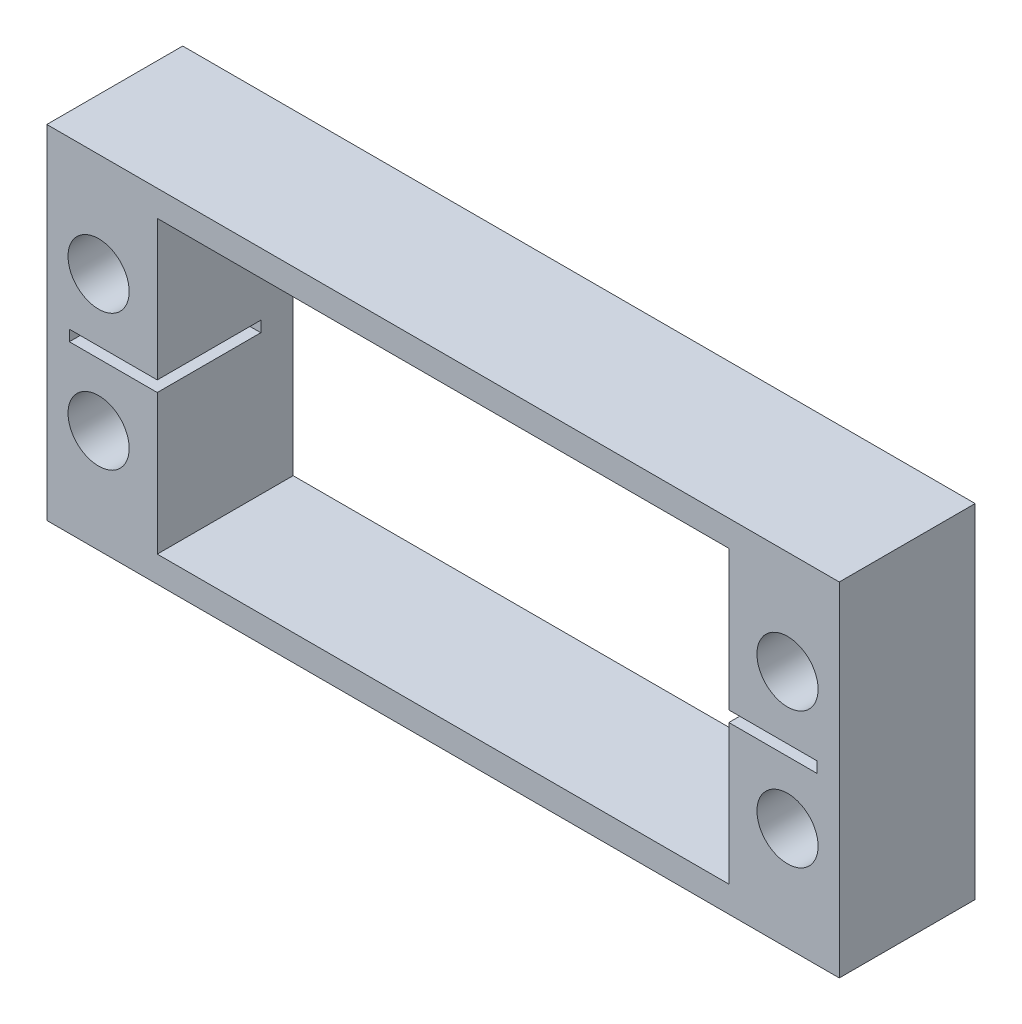
from build123d import *

# Parameters (mm, degrees)
SKETCH2_W               = 58.32
SKETCH2_H               = 25.24
BOSS_EXTRUDE1_DEPTH     = 5
SKETCH1_R               = 2.25
SKETCH1_R_2             = 2.250000002
SKETCH1_R_3             = 2.250018527
CUT_EXTRUDE1_DEPTH      = 6
CUT_EXTRUDE1_DEPTH_BACK = 6
SKETCH3_W               = 42.063996433
SKETCH3_H               = 21.40000003
CUT_EXTRUDE2_DEPTH      = 1
CUT_EXTRUDE2_DEPTH_BACK = 11
SKETCH4_W               = 6.47
SKETCH4_H               = 0.8
CUT_EXTRUDE3_DEPTH      = 7.62


with BuildPart() as part:
    # Sketch2 → Boss-Extrude1 (new body, symmetric)
    with BuildSketch(Plane.XY):
        with Locations((50.422024802, 33.939282453)):
            Rectangle(SKETCH2_W, SKETCH2_H)
    extrude(amount=BOSS_EXTRUDE1_DEPTH, both=True)

    # Sketch1 → Cut-Extrude1 (cut, two sides)
    with BuildSketch(Plane.XY) as cut_extrude1_sk:
        with Locations((25.072024802, 28.939282453)):
            Circle(SKETCH1_R)
        with Locations((25.072024802, 38.939282453)):
            Circle(SKETCH1_R_2)
        with Locations((75.772021235, 38.939264272)):
            Circle(SKETCH1_R_3)
        with Locations((75.772024802, 28.939282453)):
            Circle(SKETCH1_R)
    extrude(amount=CUT_EXTRUDE1_DEPTH, mode=Mode.SUBTRACT)
    extrude(cut_extrude1_sk.sketch, amount=-CUT_EXTRUDE1_DEPTH_BACK, mode=Mode.SUBTRACT)

    # Sketch3 → Cut-Extrude2 (cut, two sides)
    with BuildSketch(Plane.XY.offset(5)) as cut_extrude2_sk:
        with Locations((50.422023018, 33.939282438)):
            Rectangle(SKETCH3_W, SKETCH3_H)
    extrude(amount=CUT_EXTRUDE2_DEPTH, mode=Mode.SUBTRACT)
    extrude(cut_extrude2_sk.sketch, amount=-CUT_EXTRUDE2_DEPTH_BACK, mode=Mode.SUBTRACT)

    # Sketch4 → Cut-Extrude3 (cut)
    with BuildSketch(Plane(origin=(0, 0, 5), x_dir=(-1, 0, 0), z_dir=(0, 0, -1))):
        with Locations((-74.689021235, 33.939282453)):
            Rectangle(SKETCH4_W, SKETCH4_H)
        with Locations((-26.155024802, 33.939282453)):
            Rectangle(SKETCH4_W, SKETCH4_H)
    extrude(amount=CUT_EXTRUDE3_DEPTH, mode=Mode.SUBTRACT)


solid = part.part
